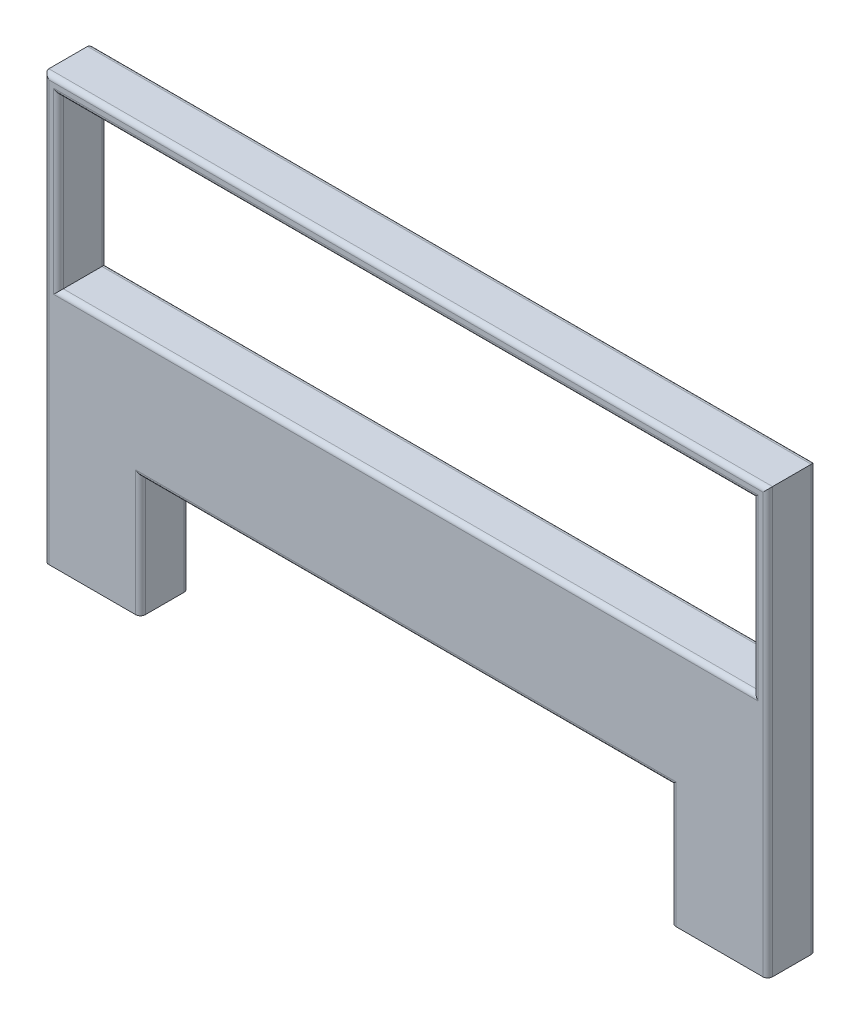
from build123d import *

# Parameters (mm, degrees)
SKETCH1_W           = 1440
SKETCH1_H           = 350
BOSS_EXTRUDE1_DEPTH = 100
FILLET1_R           = 10


with BuildPart() as part:
    # Sketch1 → Boss-Extrude1 (new body)
    with BuildSketch(Plane.XY):
        Polygon((629.663880273, -500), (429.663880273, -500), (429.663880273, -250), (-670.336119727, -250), (-670.336119727, -500), (-870.336119727, -500), (-870.336119727, 380), (629.663880273, 380), align=None)
        with Locations((-120.336119727, 175)):
            Rectangle(SKETCH1_W, SKETCH1_H, mode=Mode.SUBTRACT)
    extrude(amount=BOSS_EXTRUDE1_DEPTH)

    # Fillet1
    fillet1_edges = [part.edges().sort_by_distance(p)[0] for p in [
        (429.663880273, -375, 0),
        (-120.336119727, -250, 0),
        (-670.336119727, -375, 0),
        (429.663880273, -375, 100),
        (629.663880273, -60, 100),
        (-840.336119727, 175, 0),
        (-120.336119727, 0, 0),
        (-120.336119727, 380, 100),
        (599.663880273, 175, 0),
        (-120.336119727, 350, 0),
        (-840.336119727, 175, 100),
        (-120.336119727, 0, 100),
        (599.663880273, 175, 100),
        (-120.336119727, 350, 100),
        (-870.336119727, -60, 100),
        (-670.336119727, -375, 100),
        (-120.336119727, -250, 100),
        (-870.336119727, -60, 0),
        (-120.336119727, 380, 0),
        (629.663880273, -60, 0),
    ]]
    fillet(fillet1_edges, radius=FILLET1_R)


solid = part.part
